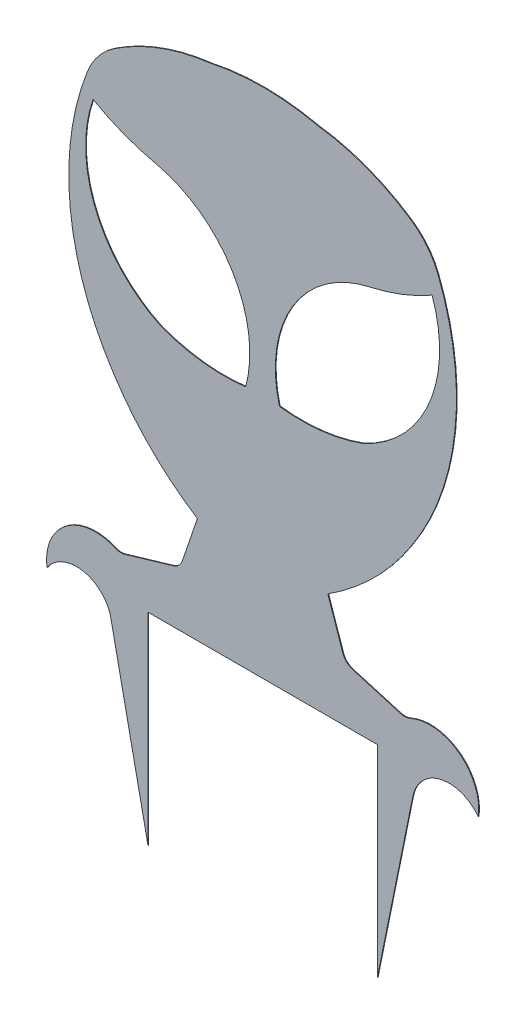
from build123d import *

# Parameters (mm, degrees)
SALIENTE_EXTRUIR1_DEPTH = 0.1


with BuildPart() as part:
    # Model → Saliente-Extruir1 (new body)
    with BuildSketch(Plane.XY):
        with BuildLine():
            Line((14.520286295, 27.479285465), (30.020286295, 27.479285465))
            Line((30.020286295, 27.479285465), (30.995526762, 27.479285465))
            Line((30.995526762, 27.479285465), (46.520286295, 27.479285465))
            Line((46.520286295, 27.479285465), (46.520286295, -0.733231614))
            Line((46.520286295, -0.733231614), (51.471061016, 23.659269995))
            ThreePointArc((51.471061016, 23.659269995), (55.350844588, 27.68663731), (60.617590106, 25.806796971))
            ThreePointArc((60.617590106, 25.806796971), (57.96035452, 32.1636369), (51.115344163, 32.948587895))
            ThreePointArc((51.115344163, 32.948587895), (50.436854059, 32.782110426), (49.742499175, 32.859148502))
            Line((49.742499175, 32.859148502), (43.04104749, 34.830163703))
            ThreePointArc((43.04104749, 34.830163703), (42.188067529, 35.337786997), (41.684191584, 36.192985954))
            Line((41.684191584, 36.192985954), (39.61828219, 42.24428199))
            ThreePointArc((39.61828219, 42.24428199), (46.085307041, 47.434632953), (51.291287848, 53.889082378))
            ThreePointArc((51.291287848, 53.889082378), (57.354652208, 70.765408557), (54.99199246, 88.541589574))
            ThreePointArc((54.99199246, 88.541589574), (53.468862534, 91.179848081), (51.222076914, 93.237100398))
            ThreePointArc((51.222076914, 93.237100398), (45.021608732, 96.446811627), (38.244470176, 98.125634086))
            ThreePointArc((38.244470176, 98.125634086), (30.716762072, 98.976544856), (23.183606681, 98.175290659))
            ThreePointArc((23.183606681, 98.175290659), (16.202528521, 96.493815521), (9.804335921, 93.234069768))
            ThreePointArc((9.804335921, 93.234069768), (7.557851393, 91.176488668), (6.035107577, 88.538007288))
            ThreePointArc((6.035107577, 88.538007288), (3.675049302, 70.761480699), (9.740883355, 53.886042041))
            ThreePointArc((9.740883355, 53.886042041), (14.947788987, 47.432374192), (21.41554616, 42.242979995))
            Line((21.41554616, 42.242979995), (19.35050339, 36.191373826))
            ThreePointArc((19.35050339, 36.191373826), (18.846750914, 35.336102135), (17.993844246, 34.828355703))
            Line((17.993844246, 34.828355703), (11.292677181, 32.856373051))
            ThreePointArc((11.292677181, 32.856373051), (10.598333426, 32.779234734), (9.919819295, 32.945614249))
            ThreePointArc((9.919819295, 32.945614249), (3.074922331, 32.159675066), (0.418604493, 25.802451585))
            ThreePointArc((0.418604493, 25.802451585), (5.241056245, 27.958298833), (9.263373954, 24.534167044))
            Line((9.263373954, 24.534167044), (14.520286295, -0.733231614))
            Line((14.520286295, -0.733231614), (14.520286295, 27.479285465))
        make_face()
        with BuildLine():
            ThreePointArc((28.153211973, 61.525805428), (26.284358187, 74.589260971), (15.542822199, 82.255152297))
            ThreePointArc((15.542822199, 82.255152297), (11.073088945, 83.602659269), (6.85998466, 85.613639796))
            ThreePointArc((6.85998466, 85.613639796), (7.253715162, 72.399202471), (16.442622696, 62.89444809))
            ThreePointArc((16.442622696, 62.89444809), (22.215756006, 61.507125455), (28.153211973, 61.525805428))
        make_face(mode=Mode.SUBTRACT)
        with BuildLine():
            ThreePointArc((32.866716238, 61.523161648), (38.809998945, 61.505477347), (44.588230247, 62.896507568))
            ThreePointArc((44.588230247, 62.896507568), (53.775746714, 72.402606594), (54.167543352, 85.617101397))
            ThreePointArc((54.167543352, 85.617101397), (49.954733408, 83.605504327), (45.485197402, 82.257343249))
            ThreePointArc((45.485197402, 82.257343249), (34.736372016, 74.592110583), (32.866716238, 61.523161648))
        make_face(mode=Mode.SUBTRACT)
    extrude(amount=SALIENTE_EXTRUIR1_DEPTH)


solid = part.part
